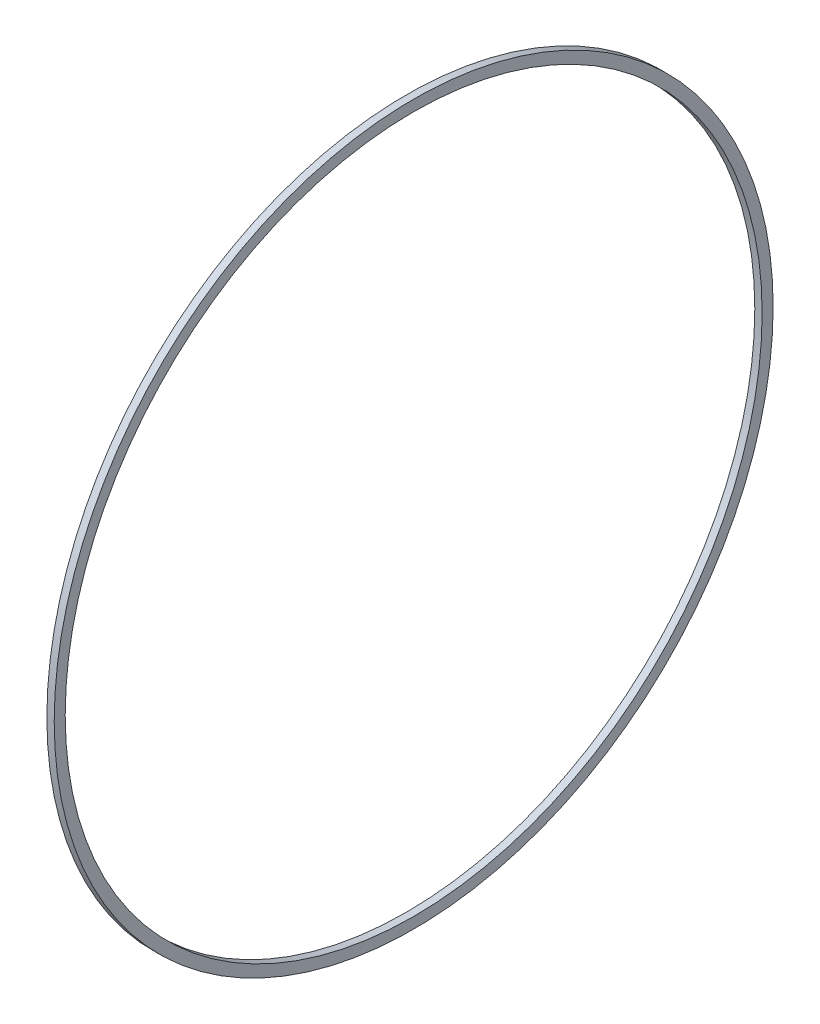
from build123d import *

# Parameters (mm, degrees)
SKETCH1_R           = 49
SKETCH1_R_2         = 47.5
BOSS_EXTRUDE1_DEPTH = 1


with BuildPart() as part:
    # Sketch1 → Boss-Extrude1 (new body)
    with BuildSketch(Plane(origin=(0, 0, 0), x_dir=(0, 0, -1), z_dir=(1, 0, 0))):
        Circle(SKETCH1_R)
        Circle(SKETCH1_R_2, mode=Mode.SUBTRACT)
    extrude(amount=BOSS_EXTRUDE1_DEPTH)


solid = part.part
